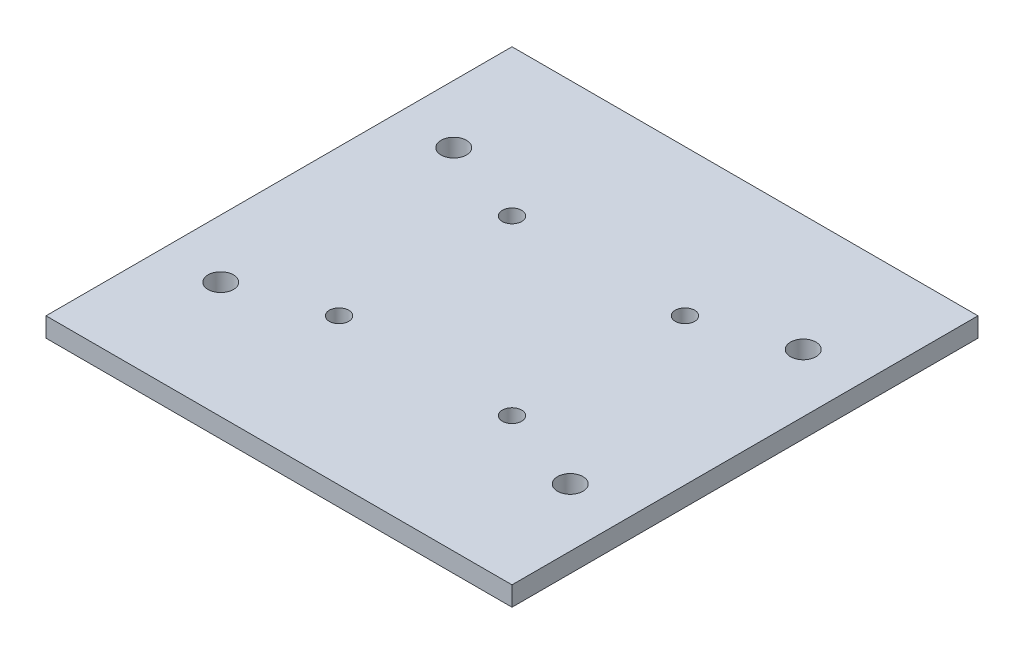
from build123d import *

# Parameters (mm, degrees)
SKETCH1_W               = 152.4
SKETCH1_H               = 152.4
BOSS_EXTRUDE1_DEPTH     = 6.35
SKETCH2_R               = 4.1656
SKETCH2_R_2             = 3.175
CUT_EXTRUDE1_DEPTH      = 1
CUT_EXTRUDE1_DEPTH_BACK = 7.35


with BuildPart() as part:
    # Sketch1 → Boss-Extrude1 (new body)
    with BuildSketch(Plane(origin=(0, 0, 0), x_dir=(1, 0, 0), z_dir=(0, 1, 0))):
        with Locations((76.2, 76.2)):
            Rectangle(SKETCH1_W, SKETCH1_H)
    extrude(amount=BOSS_EXTRUDE1_DEPTH)

    # Sketch2 → Cut-Extrude1 (cut, two sides)
    with BuildSketch(Plane(origin=(0, 6.35, 0), x_dir=(1, 0, 0), z_dir=(0, 1, 0))) as cut_extrude1_sk:
        with Locations((19.05, 38.1)):
            Circle(SKETCH2_R)
        with Locations((19.05, 114.3)):
            Circle(SKETCH2_R)
        with Locations((133.35, 114.3)):
            Circle(SKETCH2_R)
        with Locations((133.35, 38.1)):
            Circle(SKETCH2_R)
        with Locations((104.484271247, 104.484271247)):
            Circle(SKETCH2_R_2)
        with Locations((47.915728753, 47.915728753)):
            Circle(SKETCH2_R_2)
        with Locations((47.915728753, 104.484271247)):
            Circle(SKETCH2_R_2)
        with Locations((104.484271247, 47.915728753)):
            Circle(SKETCH2_R_2)
    extrude(amount=CUT_EXTRUDE1_DEPTH, mode=Mode.SUBTRACT)
    extrude(cut_extrude1_sk.sketch, amount=-CUT_EXTRUDE1_DEPTH_BACK, mode=Mode.SUBTRACT)


solid = part.part
